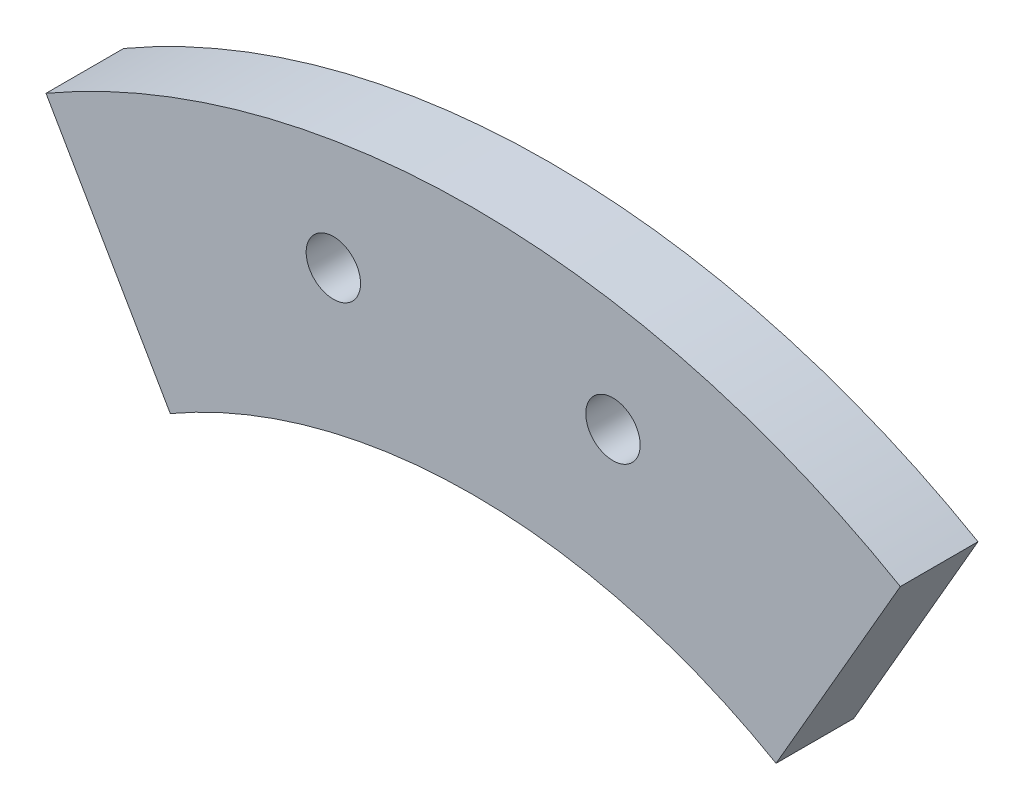
from build123d import *

# Parameters (mm, degrees)
ESQUISSE2_R             = 1.75
BOSS_EXTRU_1_DEPTH      = 5
ESQUISSE3_R             = 39
ENL_V_MAT_EXTRU_1_DEPTH = 6


with BuildPart() as part:
    # Esquisse2 → Boss.-Extru.1 (new body)
    with BuildSketch(Plane.XY):
        with BuildLine():
            Line((0, 0), (27.5, 47.631397208))
            ThreePointArc((27.5, 47.631397208), (0, 55), (-27.5, 47.631397208))
            Line((-27.5, 47.631397208), (0, 0))
        make_face()
        with Locations((-9, 47.148700937)):
            Circle(ESQUISSE2_R, mode=Mode.SUBTRACT)
        with Locations((9, 47.148700937)):
            Circle(ESQUISSE2_R, mode=Mode.SUBTRACT)
    extrude(amount=BOSS_EXTRU_1_DEPTH)

    # Esquisse3 → Enlèv. mat.-Extru.1 (cut, through all)
    with BuildSketch(Plane(origin=(0, 0, 0), x_dir=(-1, 0, 0), z_dir=(0, 0, -1))):
        Circle(ESQUISSE3_R)
    extrude(amount=-ENL_V_MAT_EXTRU_1_DEPTH, mode=Mode.SUBTRACT)


solid = part.part
